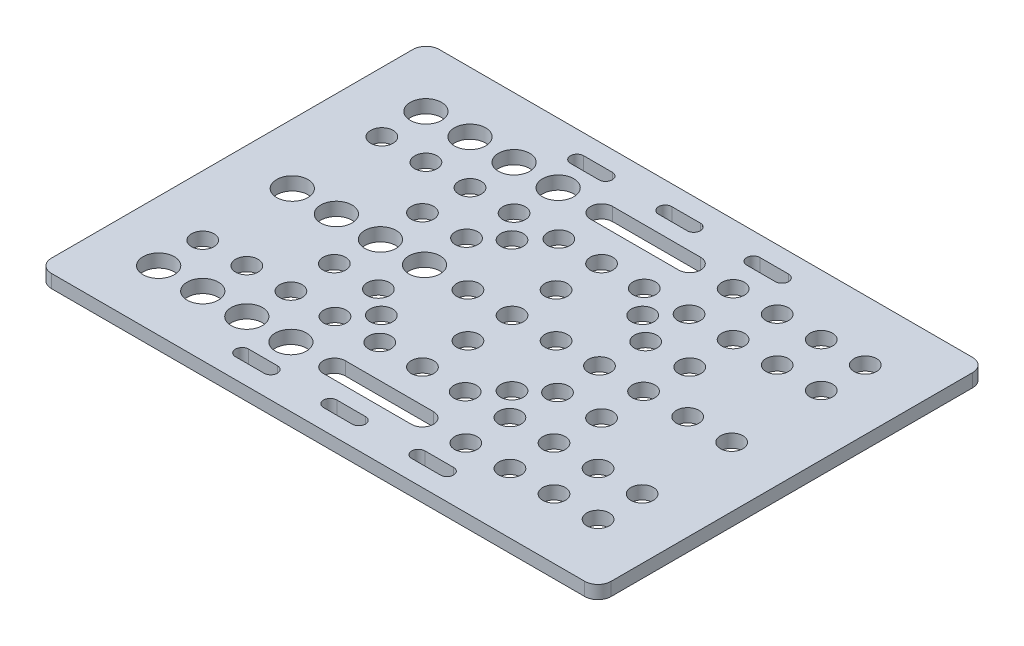
from build123d import *

# Parameters (mm, degrees)
SKETCH1_R           = 3.55
SKETCH1_R_2         = 2.55
BOSS_EXTRUDE1_DEPTH = 3


with BuildPart() as part:
    # Sketch1 → Boss-Extrude1 (new body)
    with BuildSketch(Plane(origin=(0, 0, 0), x_dir=(1, 0, 0), z_dir=(0, 1, 0))):
        with BuildLine():
            Line((60.5, -44), (-60.5, -44))
            ThreePointArc((-60.5, -44), (-62.621320344, -43.121320344), (-63.5, -41))
            Line((-63.5, -41), (-63.5, 41))
            ThreePointArc((-63.5, 41), (-62.621320344, 43.121320344), (-60.5, 44))
            Line((-60.5, 44), (60.5, 44))
            ThreePointArc((60.5, 44), (62.621320344, 43.121320344), (63.5, 41))
            Line((63.5, 41), (63.5, -41))
            ThreePointArc((63.5, -41), (62.621320344, -43.121320344), (60.5, -44))
        make_face()
        with Locations((-39.85, 30.32)):
            Circle(SKETCH1_R, mode=Mode.SUBTRACT)
        with Locations((0, 10)):
            Circle(SKETCH1_R_2, mode=Mode.SUBTRACT)
        Circle(SKETCH1_R_2, mode=Mode.SUBTRACT)
        with Locations((10, 0)):
            Circle(SKETCH1_R_2, mode=Mode.SUBTRACT)
        with Locations((-10, 0)):
            Circle(SKETCH1_R_2, mode=Mode.SUBTRACT)
        with Locations((-49.85, 30.32)):
            Circle(SKETCH1_R, mode=Mode.SUBTRACT)
        with Locations((-49.85, 0)):
            Circle(SKETCH1_R, mode=Mode.SUBTRACT)
        with Locations((-49.85, -30.32)):
            Circle(SKETCH1_R, mode=Mode.SUBTRACT)
        with Locations((-20.32, 10)):
            Circle(SKETCH1_R_2, mode=Mode.SUBTRACT)
        with Locations((-30.32, 10)):
            Circle(SKETCH1_R_2, mode=Mode.SUBTRACT)
        with Locations((-14.825, 14.825)):
            Circle(SKETCH1_R_2, mode=Mode.SUBTRACT)
        with Locations((0, 20.32)):
            Circle(SKETCH1_R_2, mode=Mode.SUBTRACT)
        with Locations((-49.85, 20.32)):
            Circle(SKETCH1_R_2, mode=Mode.SUBTRACT)
        with Locations((-39.85, 20.32)):
            Circle(SKETCH1_R_2, mode=Mode.SUBTRACT)
        with Locations((-29.85, 20.32)):
            Circle(SKETCH1_R_2, mode=Mode.SUBTRACT)
        with Locations((-39.85, 0)):
            Circle(SKETCH1_R, mode=Mode.SUBTRACT)
        with Locations((14.825, 14.825)):
            Circle(SKETCH1_R_2, mode=Mode.SUBTRACT)
        with Locations((20.32, 10)):
            Circle(SKETCH1_R_2, mode=Mode.SUBTRACT)
        with Locations((30.32, 10)):
            Circle(SKETCH1_R_2, mode=Mode.SUBTRACT)
        with Locations((39.85, 30.32)):
            Circle(SKETCH1_R_2, mode=Mode.SUBTRACT)
        with Locations((49.85, 30.32)):
            Circle(SKETCH1_R_2, mode=Mode.SUBTRACT)
        with Locations((49.85, 0)):
            Circle(SKETCH1_R_2, mode=Mode.SUBTRACT)
        with Locations((30.32, -10)):
            Circle(SKETCH1_R_2, mode=Mode.SUBTRACT)
        with Locations((49.85, -30.32)):
            Circle(SKETCH1_R_2, mode=Mode.SUBTRACT)
        with Locations((29.85, 30.32)):
            Circle(SKETCH1_R_2, mode=Mode.SUBTRACT)
        with Locations((20.32, -10)):
            Circle(SKETCH1_R_2, mode=Mode.SUBTRACT)
        with Locations((0, -10)):
            Circle(SKETCH1_R_2, mode=Mode.SUBTRACT)
        with Locations((14.825, -14.825)):
            Circle(SKETCH1_R_2, mode=Mode.SUBTRACT)
        with Locations((-29.85, 0)):
            Circle(SKETCH1_R, mode=Mode.SUBTRACT)
        with Locations((-19.85, 20.32)):
            Circle(SKETCH1_R_2, mode=Mode.SUBTRACT)
        with Locations((-9.69, 20.32)):
            Circle(SKETCH1_R_2, mode=Mode.SUBTRACT)
        with Locations((9.69, 20.32)):
            Circle(SKETCH1_R_2, mode=Mode.SUBTRACT)
        with Locations((-19.85, 0)):
            Circle(SKETCH1_R, mode=Mode.SUBTRACT)
        with Locations((-14.825, -14.825)):
            Circle(SKETCH1_R_2, mode=Mode.SUBTRACT)
        with Locations((-20.32, -10)):
            Circle(SKETCH1_R_2, mode=Mode.SUBTRACT)
        with Locations((-30.32, -10)):
            Circle(SKETCH1_R_2, mode=Mode.SUBTRACT)
        with Locations((-29.85, 30.32)):
            Circle(SKETCH1_R, mode=Mode.SUBTRACT)
        with Locations((-19.85, 30.32)):
            Circle(SKETCH1_R, mode=Mode.SUBTRACT)
        with Locations((19.85, 30.32)):
            Circle(SKETCH1_R_2, mode=Mode.SUBTRACT)
        with Locations((19.85, 20.32)):
            Circle(SKETCH1_R_2, mode=Mode.SUBTRACT)
        with Locations((29.85, 20.32)):
            Circle(SKETCH1_R_2, mode=Mode.SUBTRACT)
        with Locations((39.85, 20.32)):
            Circle(SKETCH1_R_2, mode=Mode.SUBTRACT)
        with Locations((49.85, 20.32)):
            Circle(SKETCH1_R_2, mode=Mode.SUBTRACT)
        with Locations((39.85, 0)):
            Circle(SKETCH1_R_2, mode=Mode.SUBTRACT)
        with Locations((29.85, 0)):
            Circle(SKETCH1_R_2, mode=Mode.SUBTRACT)
        with Locations((19.85, 0)):
            Circle(SKETCH1_R_2, mode=Mode.SUBTRACT)
        with Locations((19.85, -30.32)):
            Circle(SKETCH1_R_2, mode=Mode.SUBTRACT)
        with Locations((29.85, -30.32)):
            Circle(SKETCH1_R_2, mode=Mode.SUBTRACT)
        with Locations((0, -20.32)):
            Circle(SKETCH1_R_2, mode=Mode.SUBTRACT)
        with Locations((39.85, -30.32)):
            Circle(SKETCH1_R_2, mode=Mode.SUBTRACT)
        with Locations((49.85, -20.32)):
            Circle(SKETCH1_R_2, mode=Mode.SUBTRACT)
        with Locations((39.85, -20.32)):
            Circle(SKETCH1_R_2, mode=Mode.SUBTRACT)
        with Locations((29.85, -20.32)):
            Circle(SKETCH1_R_2, mode=Mode.SUBTRACT)
        with Locations((19.85, -20.32)):
            Circle(SKETCH1_R_2, mode=Mode.SUBTRACT)
        with Locations((9.69, -20.32)):
            Circle(SKETCH1_R_2, mode=Mode.SUBTRACT)
        with Locations((-9.69, -20.32)):
            Circle(SKETCH1_R_2, mode=Mode.SUBTRACT)
        with Locations((-19.85, -20.32)):
            Circle(SKETCH1_R_2, mode=Mode.SUBTRACT)
        with Locations((-29.85, -20.32)):
            Circle(SKETCH1_R_2, mode=Mode.SUBTRACT)
        with Locations((-39.85, -20.32)):
            Circle(SKETCH1_R_2, mode=Mode.SUBTRACT)
        with Locations((-49.85, -20.32)):
            Circle(SKETCH1_R_2, mode=Mode.SUBTRACT)
        with Locations((-19.85, -30.32)):
            Circle(SKETCH1_R, mode=Mode.SUBTRACT)
        with Locations((-29.85, -30.32)):
            Circle(SKETCH1_R, mode=Mode.SUBTRACT)
        with Locations((-39.85, -30.32)):
            Circle(SKETCH1_R, mode=Mode.SUBTRACT)
        with BuildLine():
            Line((10, 27.82), (-10, 27.82))
            ThreePointArc((-10, 27.82), (-12.5, 30.32), (-10, 32.82))
            Line((-10, 32.82), (10, 32.82))
            ThreePointArc((10, 32.82), (12.5, 30.32), (10, 27.82))
        make_face(mode=Mode.SUBTRACT)
        with BuildLine():
            Line((3.25, 36.5), (-3.25, 36.5))
            ThreePointArc((-3.25, 36.5), (-4.75, 38), (-3.25, 39.5))
            Line((-3.25, 39.5), (3.25, 39.5))
            ThreePointArc((3.25, 39.5), (4.75, 38), (3.25, 36.5))
        make_face(mode=Mode.SUBTRACT)
        with BuildLine():
            Line((-16.75, 36.5), (-23.25, 36.5))
            ThreePointArc((-23.25, 36.5), (-24.75, 38), (-23.25, 39.5))
            Line((-23.25, 39.5), (-16.75, 39.5))
            ThreePointArc((-16.75, 39.5), (-15.25, 38), (-16.75, 36.5))
        make_face(mode=Mode.SUBTRACT)
        with BuildLine():
            Line((16.75, 36.5), (23.25, 36.5))
            ThreePointArc((23.25, 36.5), (24.75, 38), (23.25, 39.5))
            Line((23.25, 39.5), (16.75, 39.5))
            ThreePointArc((16.75, 39.5), (15.25, 38), (16.75, 36.5))
        make_face(mode=Mode.SUBTRACT)
        with BuildLine():
            Line((10, -27.82), (-10, -27.82))
            ThreePointArc((-10, -27.82), (-12.5, -30.32), (-10, -32.82))
            Line((-10, -32.82), (10, -32.82))
            ThreePointArc((10, -32.82), (12.5, -30.32), (10, -27.82))
        make_face(mode=Mode.SUBTRACT)
        with BuildLine():
            Line((-16.75, -36.5), (-23.25, -36.5))
            ThreePointArc((-23.25, -36.5), (-24.75, -38), (-23.25, -39.5))
            Line((-23.25, -39.5), (-16.75, -39.5))
            ThreePointArc((-16.75, -39.5), (-15.25, -38), (-16.75, -36.5))
        make_face(mode=Mode.SUBTRACT)
        with BuildLine():
            Line((3.25, -36.5), (-3.25, -36.5))
            ThreePointArc((-3.25, -36.5), (-4.75, -38), (-3.25, -39.5))
            Line((-3.25, -39.5), (3.25, -39.5))
            ThreePointArc((3.25, -39.5), (4.75, -38), (3.25, -36.5))
        make_face(mode=Mode.SUBTRACT)
        with BuildLine():
            Line((16.75, -36.5), (23.25, -36.5))
            ThreePointArc((23.25, -36.5), (24.75, -38), (23.25, -39.5))
            Line((23.25, -39.5), (16.75, -39.5))
            ThreePointArc((16.75, -39.5), (15.25, -38), (16.75, -36.5))
        make_face(mode=Mode.SUBTRACT)
    extrude(amount=BOSS_EXTRUDE1_DEPTH)


solid = part.part
